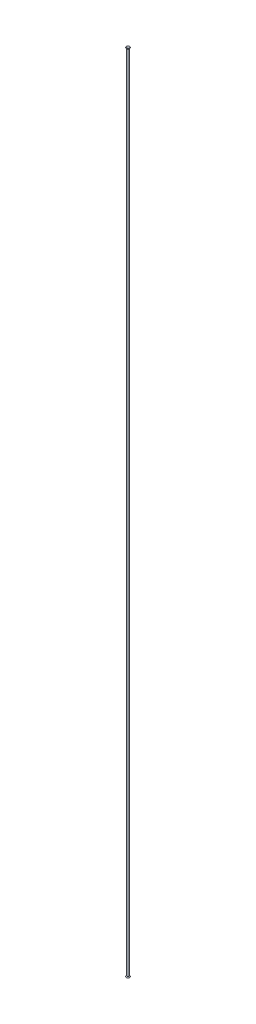
from build123d import *

# Parameters (mm, degrees)
SKETCH1_R           = 6.35
SKETCH1_R_2         = 3.175
BOSS_EXTRUDE1_DEPTH = 4705.096


with BuildPart() as part:
    # Sketch1 → Boss-Extrude1 (new body)
    with BuildSketch(Plane(origin=(0, 0, 0), x_dir=(1, 0, 0), z_dir=(0, 1, 0))):
        Circle(SKETCH1_R)
        Circle(SKETCH1_R_2, mode=Mode.SUBTRACT)
    extrude(amount=BOSS_EXTRUDE1_DEPTH)

    # Sketch2 → Revolve1 (revolve)
    with BuildSketch(Plane.XY):
        Polygon((6.35, 4705.096), (10.431701322, 4709.960382214), (8.568534839, 4711.523764522), (3.175, 4705.096), align=None)
    revolve1 = revolve(axis=Axis((0, 4946.833252748, 0), (0, -1, 0)))

    # Mirror1: Revolve1 across plane
    add(revolve1.mirror(Plane.ZX.offset(2352.548)))


solid = part.part
